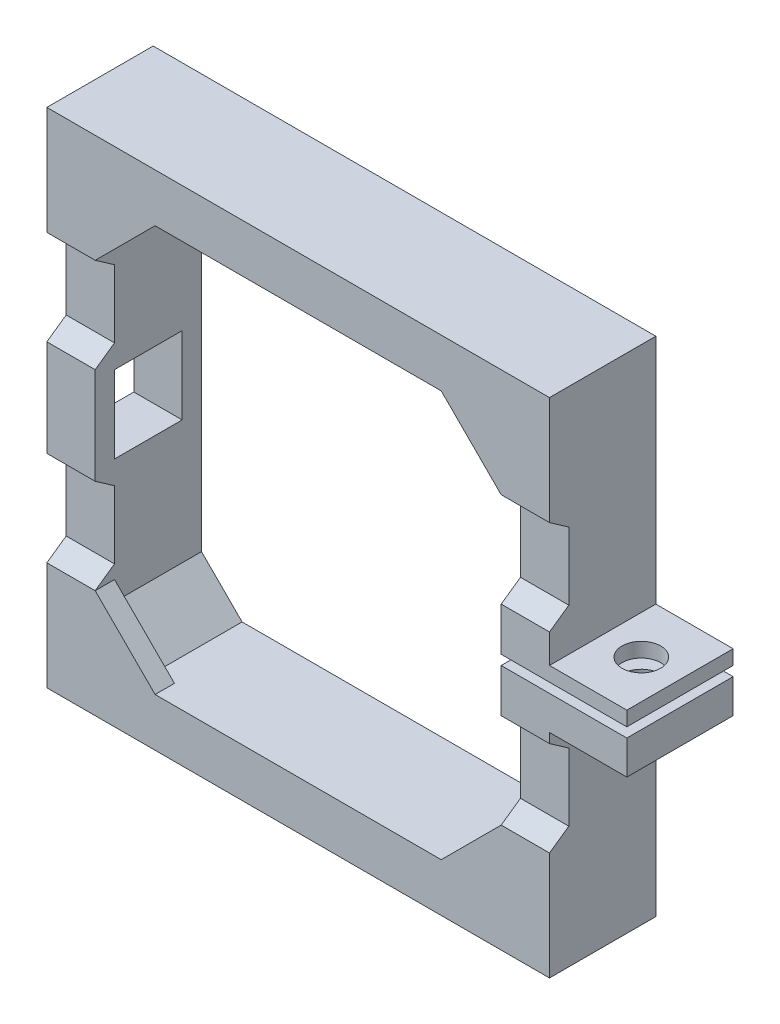
from build123d import *

# Parameters (mm, degrees)
ESQUISSE1_W             = 52
ESQUISSE1_H             = 52
ESQUISSE1_W_2           = 42
ESQUISSE1_H_2           = 42
BOSS_EXTRU_1_DEPTH      = 11
ENL_V_START             = -53
ENL_V_MAT_EXTRU_1_DEPTH = 54
BOSS_EXTRU_2_DEPTH      = 2
BOSS_EXTRU_3_DEPTH      = 9
SYM_TRIE3_COPY_1_DEPTH  = 2
SYM_TRIE3_COPY_2_DEPTH  = 9
ENL_V_MAT_EXTRU_2_REACH = 54
ESQUISSE4_W             = 7
ESQUISSE4_H             = 8
ESQUISSE7_W             = 11
ESQUISSE7_H             = 6
BOSS_EXTRU_4_DEPTH      = 8
ENL_V_MAT_EXTRU_3_REACH = 62
ESQUISSE8_W             = 11
ESQUISSE8_H             = 1
ENL_V_MAT_EXTRU_4_DEPTH = 2.5
ESQUISSE10_R            = 2
ENL_V_MAT_EXTRU_5_DEPTH = 3.5


with BuildPart() as part:
    # Esquisse1 → Boss.-Extru.1 (new body)
    with BuildSketch(Plane.XY):
        Rectangle(ESQUISSE1_W, ESQUISSE1_H)
        Rectangle(ESQUISSE1_W_2, ESQUISSE1_H_2, mode=Mode.SUBTRACT)
    extrude(amount=BOSS_EXTRU_1_DEPTH)

    # Esquisse2 → Enlèv. mat.-Extru.1 (cut)
    with BuildSketch(Plane.ZY.offset(26).offset(ENL_V_START)):
        Polygon((88.428613369, 69.000029358), (11, 14.8), (9, 13.4), (9, 6.4), (11, 5), (88.428613369, -49.200029358), (277.455948436, -49.200029358), (277.455948436, 69.000029358), align=None)
    enl_v_mat_extru_1 = extrude(amount=ENL_V_MAT_EXTRU_1_DEPTH, mode=Mode.SUBTRACT)

    # Symétrie1: Enlèv. mat.-Extru.1 across plane
    add(enl_v_mat_extru_1.mirror(Plane.ZX), mode=Mode.SUBTRACT)

    # Esquisse3 → Boss.-Extru.2 (add)
    with BuildSketch(Plane.XY.offset(11)):
        Polygon((-21, 14.8), (-14.8, 21), (-21, 21), align=None)
    boss_extru_2 = extrude(amount=-BOSS_EXTRU_2_DEPTH)

    # Esquisse6 → Boss.-Extru.3 (add)
    with BuildSketch(Plane(origin=(0, 0, 9), x_dir=(-1, 0, 0), z_dir=(0, 0, -1))):
        Polygon((21, 21), (16.8, 21), (21, 16.8), align=None)
    boss_extru_3 = extrude(amount=BOSS_EXTRU_3_DEPTH)

    # Symétrie2: Boss.-Extru.2, Boss.-Extru.3 across plane
    add(boss_extru_2.mirror(Plane(origin=(0, 0, 0), x_dir=(0, 0, 1), z_dir=(1, 0, 0))))
    add(boss_extru_3.mirror(Plane(origin=(0, 0, 0), x_dir=(0, 0, 1), z_dir=(1, 0, 0))))

    # Symétrie3: Boss.-Extru.2, Boss.-Extru.3 across plane
    add(boss_extru_2.mirror(Plane.ZX))
    add(boss_extru_3.mirror(Plane.ZX))

    # Symétrie3 copy 1 sketch → Symétrie3 copy 1 (add)
    with BuildSketch(Plane(origin=(0, 0, 11), x_dir=(-1, 0, 0), z_dir=(0, 0, 1))):
        Polygon((-21, 14.8), (-14.8, 21), (-21, 21), align=None)
    extrude(amount=-SYM_TRIE3_COPY_1_DEPTH)

    # Symétrie3 copy 2 sketch → Symétrie3 copy 2 (add)
    with BuildSketch(Plane(origin=(0, 0, 9), x_dir=(1, 0, 0), z_dir=(0, 0, -1))):
        Polygon((21, 21), (16.8, 21), (21, 16.8), align=None)
    extrude(amount=SYM_TRIE3_COPY_2_DEPTH)

    # Esquisse4 → Enlèv. mat.-Extru.2 (cut, up to next)
    with BuildSketch(Plane.ZY.offset(26), mode=Mode.PRIVATE) as enl_v_mat_extru_2_sk1:
        with Locations((5.5, 0)):
            Rectangle(ESQUISSE4_W, ESQUISSE4_H)
    enl_v_mat_extru_2_tool1 = extrude(enl_v_mat_extru_2_sk1.sketch, amount=-ENL_V_MAT_EXTRU_2_REACH, mode=Mode.PRIVATE) & part.part
    add(enl_v_mat_extru_2_tool1.solids().sort_by_distance((-26, 0, 5.5))[0], mode=Mode.SUBTRACT)

    # Esquisse7 → Boss.-Extru.4 (add)
    with BuildSketch(Plane(origin=(26, 0, 0), x_dir=(0, 0, -1), z_dir=(1, 0, 0))):
        with Locations((-5.5, -1)):
            Rectangle(ESQUISSE7_W, ESQUISSE7_H)
    extrude(amount=BOSS_EXTRU_4_DEPTH)

    # Esquisse8 → Enlèv. mat.-Extru.3 (cut, up to next)
    with BuildSketch(Plane(origin=(34, 0, 0), x_dir=(0, 0, -1), z_dir=(1, 0, 0)), mode=Mode.PRIVATE) as enl_v_mat_extru_3_sk1:
        with Locations((-5.5, 0)):
            Rectangle(ESQUISSE8_W, ESQUISSE8_H)
    enl_v_mat_extru_3_tool1 = extrude(enl_v_mat_extru_3_sk1.sketch, amount=-ENL_V_MAT_EXTRU_3_REACH, mode=Mode.PRIVATE) & part.part
    add(enl_v_mat_extru_3_tool1.solids().sort_by_distance((34, 0, 5.5))[0], mode=Mode.SUBTRACT)

    # Esquisse9 → Enlèv. mat.-Extru.4 (cut)
    with BuildSketch(Plane.XZ.offset(4)):
        Polygon((33.464101615, 5.5), (31.732050808, 8.5), (28.267949192, 8.5), (26.535898385, 5.5), (28.267949192, 2.5), (31.732050808, 2.5), align=None)
    extrude(amount=-ENL_V_MAT_EXTRU_4_DEPTH, mode=Mode.SUBTRACT)

    # Esquisse10 → Enlèv. mat.-Extru.5 (cut)
    with BuildSketch(Plane.XZ.offset(1.5)):
        with Locations((30, 5.5)):
            Circle(ESQUISSE10_R)
    extrude(amount=-ENL_V_MAT_EXTRU_5_DEPTH, mode=Mode.SUBTRACT)


solid = part.part
